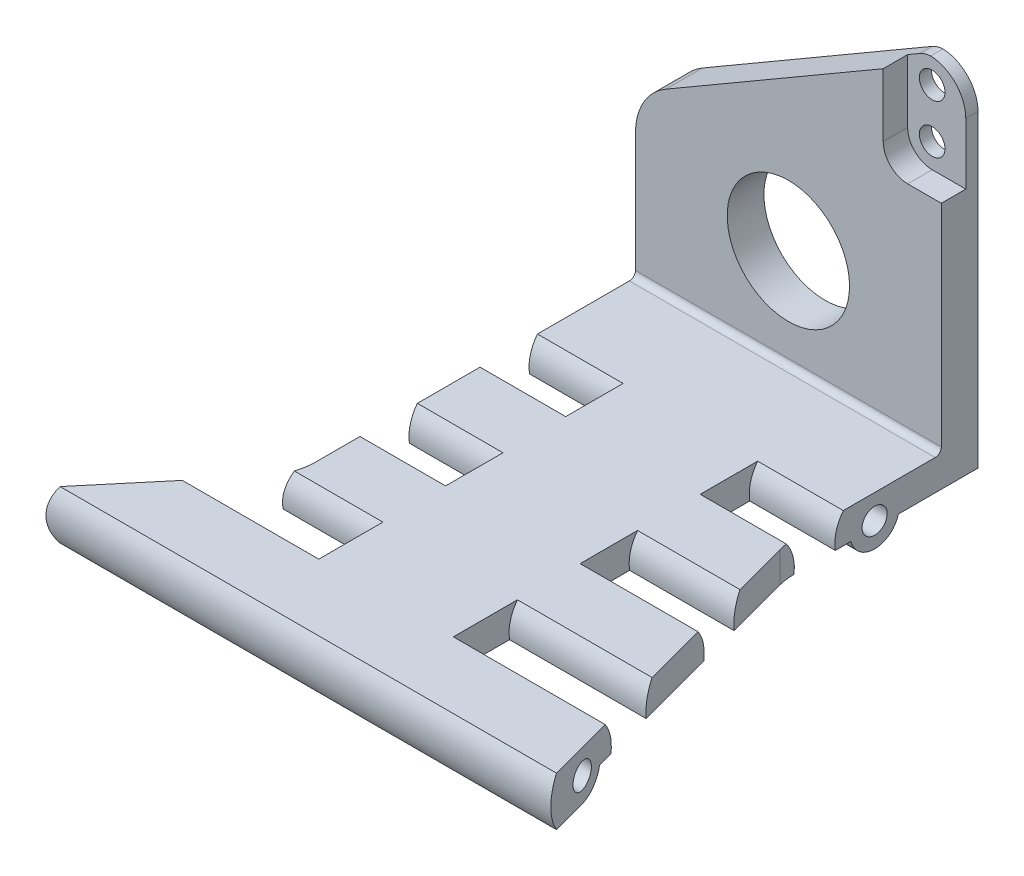
from build123d import *

# Parameters (mm, degrees)
BOSS_EXTRUDE1_DEPTH     = 8
SKETCH2_R               = 2.05
CUT_EXTRUDE1_DEPTH      = 28.707069821
CUT_EXTRUDE1_DEPTH_BACK = 68.014773719
CUT_EXTRUDE2_DEPTH      = 28.707069821
CUT_EXTRUDE2_DEPTH_BACK = 68.014773719
CUT_EXTRUDE3_DEPTH      = 19.476973879
CUT_EXTRUDE3_DEPTH_BACK = 14
CUT_EXTRUDE4_START      = -50
CUT_EXTRUDE4_DEPTH      = 14
CUT_EXTRUDE4_DEPTH_BACK = 15.067332603
BOSS_EXTRUDE2_DEPTH     = 6
FILLET8_R               = 1
SKETCH7_R               = 2.1
SKETCH7_R_2             = 10
CUT_EXTRUDE5_DEPTH      = 7
CUT_EXTRUDE6_DEPTH      = 4


with BuildPart() as part:
    # Sketch1 → Boss-Extrude1 (new body)
    with BuildSketch(Plane(origin=(0, 0, 0), x_dir=(1, 0, 0), z_dir=(0, 1, 0))):
        with BuildLine():
            Line((0, 0), (0, -52.240297657))
            ThreePointArc((0, -52.240297657), (-0.603073792, -55.660499091), (-2.339555569, -58.668173754))
            Line((-2.339555569, -58.668173754), (-27.707069821, -88.9))
            Line((-27.707069821, -88.9), (67.014773719, -88.9))
            Line((67.014773719, -88.9), (50.340741737, -26.671665475))
            ThreePointArc((50.340741737, -26.671665475), (50.085551386, -25.388736946), (50, -24.083475024))
            Line((50, -24.083475024), (50, 0))
            Line((50, 0), (0, 0))
        make_face()
    extrude(amount=BOSS_EXTRUDE1_DEPTH)

    # Sketch2 → Cut-Extrude1 (cut, two sides)
    with BuildSketch(Plane.ZY) as cut_extrude1_sk:
        with Locations((10.9, 4)):
            Circle(SKETCH2_R)
        with Locations((70.9, 4)):
            Circle(SKETCH2_R)
    extrude(amount=CUT_EXTRUDE1_DEPTH, mode=Mode.SUBTRACT)
    extrude(cut_extrude1_sk.sketch, amount=-CUT_EXTRUDE1_DEPTH_BACK, mode=Mode.SUBTRACT)

    # Sketch4 → Cut-Extrude2 (cut, two sides)
    with BuildSketch(Plane.ZY) as cut_extrude2_sk:
        with BuildLine():
            Line((67.027016654, 3), (14.772983346, 3))
            ThreePointArc((14.772983346, 3), (13.349489743, 0.83772234), (10.9, 0))
            Line((10.9, 0), (70.9, 0))
            ThreePointArc((70.9, 0), (68.450510257, 0.83772234), (67.027016654, 3))
        make_face()
        with BuildLine():
            Line((0, 0), (10.9, 0))
            ThreePointArc((10.9, 0), (8.450510257, 0.83772234), (7.027016654, 3))
            Line((7.027016654, 3), (0, 3))
            Line((0, 3), (0, 0))
        make_face()
        with BuildLine():
            ThreePointArc((76.644562647, 8), (77.9, 4), (76.644562647, 0))
            Line((76.644562647, 0), (88.9, 0))
            Line((88.9, 0), (88.9, 8))
            Line((88.9, 8), (76.644562647, 8))
        make_face()
    extrude(amount=CUT_EXTRUDE2_DEPTH, mode=Mode.SUBTRACT)
    extrude(cut_extrude2_sk.sketch, amount=-CUT_EXTRUDE2_DEPTH_BACK, mode=Mode.SUBTRACT)

    # Sketch5 → Cut-Extrude3 (cut, two sides)
    with BuildSketch(Plane.ZY) as cut_extrude3_sk:
        with BuildLine():
            Line((30.53333333, 10.5), (10.9, 10.5))
            ThreePointArc((10.9, 10.5), (13.750438563, 9.841660723), (16.023475383, 8))
            Line((16.023475383, 8), (25.409857947, 8))
            ThreePointArc((25.409857947, 8), (27.682894767, 9.841660723), (30.53333333, 10.5))
        make_face()
        with BuildLine():
            Line((25.409857947, 8), (16.023475383, 8))
            ThreePointArc((16.023475383, 8), (17.046242348, 6.115113473), (17.4, 4))
            ThreePointArc((17.4, 4), (17.380625197, 3.498505175), (17.322616289, 3))
            Line((17.322616289, 3), (24.110717041, 3))
            ThreePointArc((24.110717041, 3), (24.242223871, 5.634607529), (25.409857947, 8))
        make_face()
        with BuildLine():
            Line((45.043191277, 8), (35.656808713, 8))
            ThreePointArc((35.656808713, 8), (36.824442789, 5.634607529), (36.955949619, 3))
            Line((36.955949619, 3), (43.744050371, 3))
            ThreePointArc((43.744050371, 3), (43.875557201, 5.634607529), (45.043191277, 8))
        make_face()
        with BuildLine():
            Line((50.166666628, 10.5), (30.53333333, 10.5))
            ThreePointArc((30.53333333, 10.5), (33.383771893, 9.841660723), (35.656808713, 8))
            Line((35.656808713, 8), (45.043191277, 8))
            ThreePointArc((45.043191277, 8), (47.316228083, 9.841660716), (50.166666628, 10.5))
        make_face()
        with BuildLine():
            Line((70.9, 10.5), (50.166666628, 10.5))
            ThreePointArc((50.166666628, 10.5), (55.103771064, 8.227883644), (56.589282949, 3))
            Line((56.589282949, 3), (64.477383711, 3))
            ThreePointArc((64.477383711, 3), (65.962895585, 8.227883631), (70.9, 10.5))
        make_face()
    extrude(amount=CUT_EXTRUDE3_DEPTH, mode=Mode.SUBTRACT)
    extrude(cut_extrude3_sk.sketch, amount=-CUT_EXTRUDE3_DEPTH_BACK, mode=Mode.SUBTRACT)

    # Sketch5_3 → Cut-Extrude4 (cut, two sides)
    with BuildSketch(Plane.ZY.offset(CUT_EXTRUDE4_START)) as cut_extrude4_sk:
        with BuildLine():
            Line((25.409857947, 8), (16.023475383, 8))
            ThreePointArc((16.023475383, 8), (17.046242348, 6.115113473), (17.4, 4))
            ThreePointArc((17.4, 4), (17.380625197, 3.498505175), (17.322616289, 3))
            Line((17.322616289, 3), (24.110717041, 3))
            ThreePointArc((24.110717041, 3), (24.242223871, 5.634607529), (25.409857947, 8))
        make_face()
        with BuildLine():
            Line((45.043191277, 8), (35.656808713, 8))
            ThreePointArc((35.656808713, 8), (36.824442789, 5.634607529), (36.955949619, 3))
            Line((36.955949619, 3), (43.744050371, 3))
            ThreePointArc((43.744050371, 3), (43.875557201, 5.634607529), (45.043191277, 8))
        make_face()
        with BuildLine():
            Line((70.9, 10.5), (50.166666628, 10.5))
            ThreePointArc((50.166666628, 10.5), (55.103771064, 8.227883644), (56.589282949, 3))
            Line((56.589282949, 3), (64.477383711, 3))
            ThreePointArc((64.477383711, 3), (65.962895585, 8.227883631), (70.9, 10.5))
        make_face()
    extrude(amount=CUT_EXTRUDE4_DEPTH, mode=Mode.SUBTRACT)
    extrude(cut_extrude4_sk.sketch, amount=-CUT_EXTRUDE4_DEPTH_BACK, mode=Mode.SUBTRACT)

    # Sketch6 → Boss-Extrude2 (add)
    with BuildSketch(Plane(origin=(0, 0, 0), x_dir=(-1, 0, 0), z_dir=(0, 0, -1))):
        with BuildLine():
            Line((-50, 3), (0, 3))
            Line((0, 3), (0, 53.5))
            ThreePointArc((0, 53.5), (-1.757359313, 57.742640687), (-6, 59.5))
            Line((-6, 59.5), (-44, 59.5))
            ThreePointArc((-44, 59.5), (-48.242640687, 57.742640687), (-50, 53.5))
            Line((-50, 53.5), (-50, 3))
        make_face()
    extrude(amount=BOSS_EXTRUDE2_DEPTH)

    # Fillet8
    fillet8_edges = [part.edges().sort_by_distance(p)[0] for p in [
        (25, 8, 0),
    ]]
    fillet(fillet8_edges, radius=FILLET8_R)

    # Sketch7 → Cut-Extrude5 (cut, through all)
    with BuildSketch(Plane.XY):
        with BuildLine():
            ThreePointArc((0, 28.497233906), (1.331973251, 33.483746944), (4.973062456, 37.141879586))
            Line((4.973062456, 37.141879586), (42.489224982, 58.957858272))
            ThreePointArc((42.489224982, 58.957858272), (43.458710676, 59.362087071), (44.5, 59.5))
            Line((44.5, 59.5), (0, 59.5))
            Line((0, 59.5), (0, 28.497233906))
        make_face()
        with Locations((44.5, 47.5)):
            Circle(SKETCH7_R)
        with Locations((44.5, 55.5)):
            Circle(SKETCH7_R)
        with Locations((25, 24.254421738)):
            Circle(SKETCH7_R_2)
    extrude(amount=-CUT_EXTRUDE5_DEPTH, mode=Mode.SUBTRACT)

    # Sketch8 → Cut-Extrude6 (cut)
    with BuildSketch(Plane.XY):
        with BuildLine():
            Line((40.5, 47.5), (40.5, 55.5))
            Line((40.5, 55.5), (40.5, 57.801106438))
            Line((40.5, 57.801106438), (40.5, 59.687082669))
            Line((40.5, 59.687082669), (50, 59.687082669))
            Line((50, 59.687082669), (50, 43.5))
            Line((50, 43.5), (44.5, 43.5))
            ThreePointArc((44.5, 43.5), (41.671572875, 44.671572875), (40.5, 47.5))
        make_face()
    extrude(amount=-CUT_EXTRUDE6_DEPTH, mode=Mode.SUBTRACT)


solid = part.part
